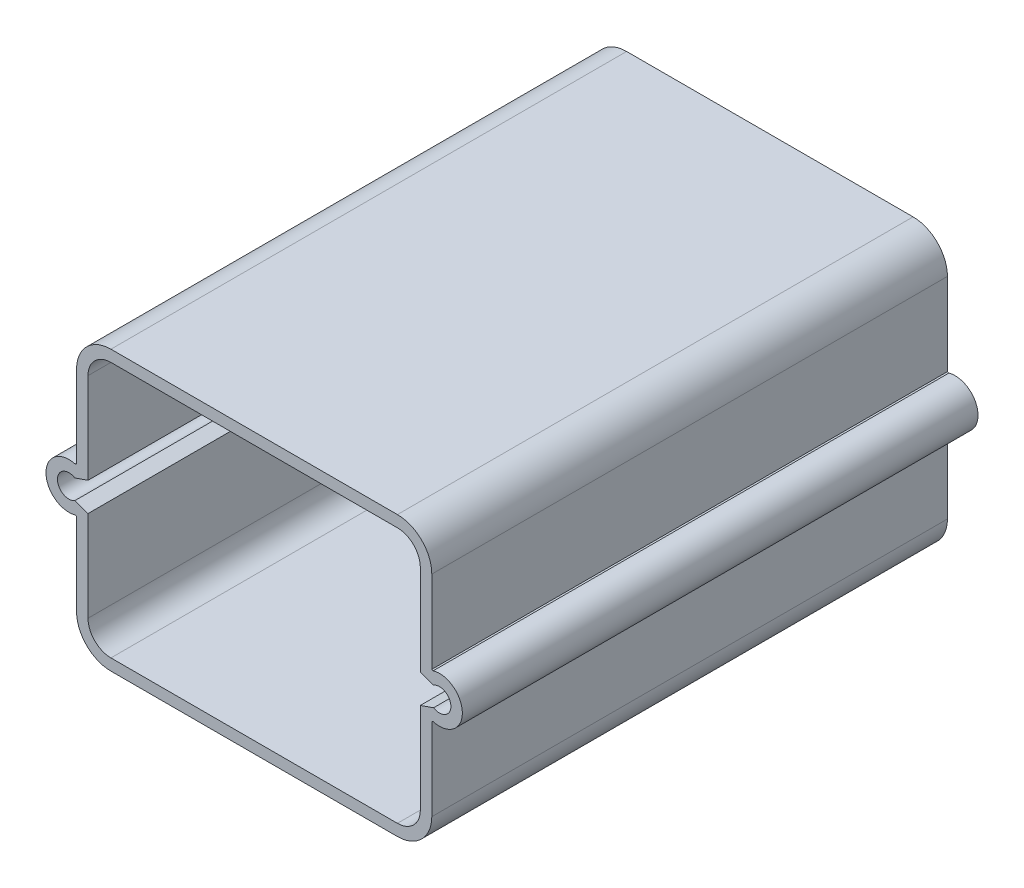
from build123d import *

# Parameters (mm, degrees)
EXTRUDE_THIN1_DEPTH = 135
SKETCH6_R           = 3.429
BOSS_EXTRUDE1_DEPTH = 6
FILLET1_R           = 1


with BuildPart() as part:
    # Sketch4 → Extrude-Thin1 (new body)
    with BuildSketch(Plane.XY):
        with BuildLine():
            Line((-46.5, 27.5), (-46.5, 5.907156632))
            Line((-46.5, 5.907156632), (-46.877529279, 5.776468537))
            ThreePointArc((-46.877529279, 5.776468537), (-54.5, 0), (-46.877529279, -5.776468537))
            Line((-46.877529279, -5.776468537), (-46.5, -5.907156632))
            Line((-46.5, -5.907156632), (-46.5, -27.5))
            ThreePointArc((-46.5, -27.5), (-43.863961031, -33.863961031), (-37.5, -36.5))
            Line((-37.5, -36.5), (37.5, -36.5))
            ThreePointArc((37.5, -36.5), (43.863961031, -33.863961031), (46.5, -27.5))
            Line((46.5, -27.5), (46.5, -5.907156632))
            Line((46.5, -5.907156632), (46.877529279, -5.776468537))
            ThreePointArc((46.877529279, -5.776468537), (54.5, 0), (46.877529279, 5.776468537))
            Line((46.877529279, 5.776468537), (46.5, 5.907156632))
            Line((46.5, 5.907156632), (46.5, 27.5))
            ThreePointArc((46.5, 27.5), (43.863961031, 33.863961031), (37.5, 36.5))
            Line((37.5, 36.5), (-37.5, 36.5))
            ThreePointArc((-37.5, 36.5), (-43.863961031, 33.863961031), (-46.5, 27.5))
        make_face()
        with BuildLine():
            Line((-43.5, 27.5), (-43.5, 3.770994321))
            Line((-43.5, 3.770994321), (-46.9586126, 2.573737532))
            ThreePointArc((-46.9586126, 2.573737532), (-51.5, 0), (-46.9586126, -2.573737532))
            Line((-46.9586126, -2.573737532), (-43.5, -3.770994321))
            Line((-43.5, -3.770994321), (-43.5, -27.5))
            ThreePointArc((-43.5, -27.5), (-41.742640687, -31.742640687), (-37.5, -33.5))
            Line((-37.5, -33.5), (37.5, -33.5))
            ThreePointArc((37.5, -33.5), (41.742640687, -31.742640687), (43.5, -27.5))
            Line((43.5, -27.5), (43.5, -3.770994321))
            Line((43.5, -3.770994321), (46.9586126, -2.573737532))
            ThreePointArc((46.9586126, -2.573737532), (51.5, 0), (46.9586126, 2.573737532))
            Line((46.9586126, 2.573737532), (43.5, 3.770994321))
            Line((43.5, 3.770994321), (43.5, 27.5))
            ThreePointArc((43.5, 27.5), (41.742640687, 31.742640687), (37.5, 33.5))
            Line((37.5, 33.5), (-37.5, 33.5))
            ThreePointArc((-37.5, 33.5), (-41.742640687, 31.742640687), (-43.5, 27.5))
        make_face(mode=Mode.SUBTRACT)
    extrude(amount=EXTRUDE_THIN1_DEPTH)

    # Sketch6 → Boss-Extrude1 (add)
    with BuildSketch(Plane(origin=(0, 0, 0), x_dir=(-1, 0, 0), z_dir=(0, 0, -1))):
        with BuildLine():
            Line((-31.5, 25.830127019), (-31.5, 33.5))
            Line((-31.5, 33.5), (-37.5, 33.5))
            ThreePointArc((-37.5, 33.5), (-41.742640687, 31.742640687), (-43.5, 27.5))
            Line((-43.5, 27.5), (-43.5, 20.830127019))
            Line((-43.5, 20.830127019), (-36.5, 20.830127019))
            ThreePointArc((-36.5, 20.830127019), (-32.964466094, 22.294593113), (-31.5, 25.830127019))
        make_face()
        with Locations((-36.5, 25.830127019)):
            Circle(SKETCH6_R, mode=Mode.SUBTRACT)
        with BuildLine():
            Line((37.5, 33.5), (31.5, 33.5))
            Line((31.5, 33.5), (31.5, 25.830127019))
            ThreePointArc((31.5, 25.830127019), (32.964466094, 22.294593113), (36.5, 20.830127019))
            Line((36.5, 20.830127019), (43.5, 20.830127019))
            Line((43.5, 20.830127019), (43.5, 27.5))
            ThreePointArc((43.5, 27.5), (41.742640687, 31.742640687), (37.5, 33.5))
        make_face()
        with Locations((36.5, 25.830127019)):
            Circle(SKETCH6_R, mode=Mode.SUBTRACT)
        with BuildLine():
            Line((31.5, -25.830127019), (31.5, -33.5))
            Line((31.5, -33.5), (37.5, -33.5))
            ThreePointArc((37.5, -33.5), (41.742640687, -31.742640687), (43.5, -27.5))
            Line((43.5, -27.5), (43.5, -20.830127019))
            Line((43.5, -20.830127019), (36.5, -20.830127019))
            ThreePointArc((36.5, -20.830127019), (32.964466094, -22.294593113), (31.5, -25.830127019))
        make_face()
        with Locations((36.5, -25.830127019)):
            Circle(SKETCH6_R, mode=Mode.SUBTRACT)
        with BuildLine():
            Line((-37.5, -33.5), (-31.5, -33.5))
            Line((-31.5, -33.5), (-31.5, -25.830127019))
            ThreePointArc((-31.5, -25.830127019), (-32.964466094, -22.294593113), (-36.5, -20.830127019))
            Line((-36.5, -20.830127019), (-43.5, -20.830127019))
            Line((-43.5, -20.830127019), (-43.5, -27.5))
            ThreePointArc((-43.5, -27.5), (-41.742640687, -31.742640687), (-37.5, -33.5))
        make_face()
        with Locations((-36.5, -25.830127019)):
            Circle(SKETCH6_R, mode=Mode.SUBTRACT)
    extrude(amount=-BOSS_EXTRUDE1_DEPTH)

    # Fillet1
    fillet1_edges = [part.edges().sort_by_distance(p)[0] for p in [
        (-40, 20.830127019, 6),
        (-32.964466094, 22.294593113, 6),
        (-31.5, 29.665063509, 6),
        (-32.964466094, -22.294593113, 6),
        (-40, -20.830127019, 6),
        (-31.5, -29.665063509, 6),
        (40, -20.830127019, 6),
        (32.964466094, -22.294593113, 6),
        (31.5, -29.665063509, 6),
        (32.964466094, 22.294593113, 6),
        (40, 20.830127019, 6),
        (31.5, 29.665063509, 6),
    ]]
    fillet(fillet1_edges, radius=FILLET1_R)


solid = part.part
